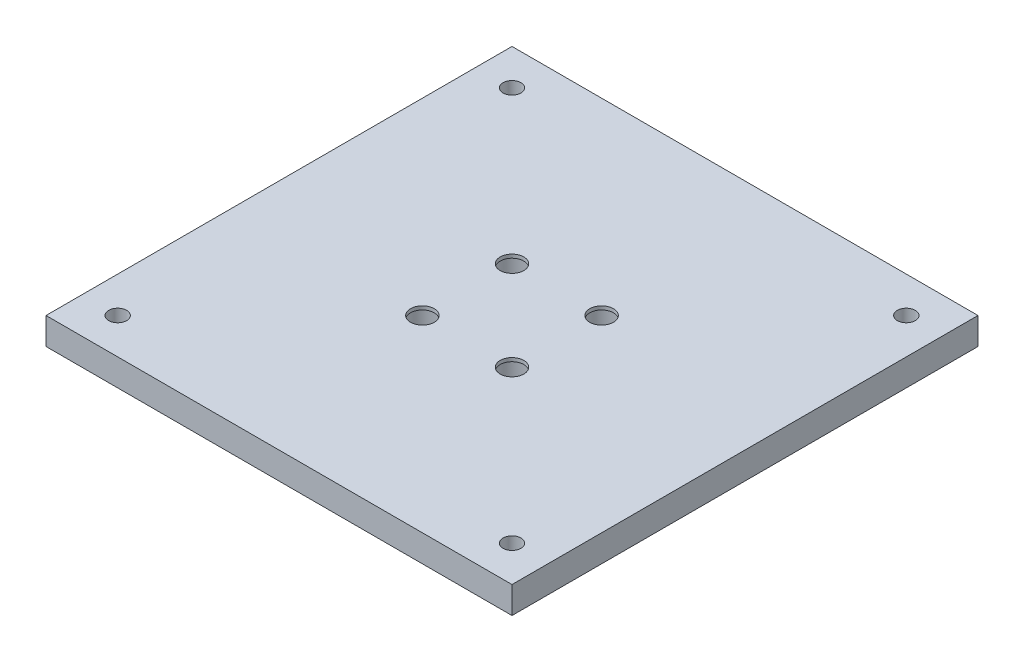
from build123d import *

# Parameters (mm, degrees)
SKETCH_1_W          = 130
SKETCH_1_H          = 130
EXTRUDE_1_DEPTH     = 7.5
HOLE_WIZARD_M6_2_D  = 5
SKETCH_6_R          = 5.4
CUT_EXTRUDE_1_DEPTH = 6.5
SKETCH_7_R          = 3.3
CUT_EXTRUDE_2_DEPTH = 2


with BuildPart() as part:
    # 草图1 → 凸台-拉伸1 (new body)
    with BuildSketch(Plane(origin=(0, 0, 0), x_dir=(1, 0, 0), z_dir=(0, 1, 0))):
        with Locations((65, 65)):
            Rectangle(SKETCH_1_W, SKETCH_1_H)
    extrude(amount=EXTRUDE_1_DEPTH)

    # M6 螺纹孔2 (through all)
    with Locations(Plane(origin=(10, 7.5, -120), x_dir=(0, 0, 1), z_dir=(0, 1, 0))):
        with Locations((0, 0), (0, 110), (110, 110), (110, 0)):
            Hole(HOLE_WIZARD_M6_2_D / 2)

    # 草图6 → 切除-拉伸1 (cut)
    with BuildSketch(Plane(origin=(0, 0, 0), x_dir=(-1, 0, 0), z_dir=(0, -1, 0))):
        with Locations((-52.5, 52.5)):
            Circle(SKETCH_6_R)
        with Locations((-77.5, 52.5)):
            Circle(SKETCH_6_R)
        with Locations((-52.5, 77.5)):
            Circle(SKETCH_6_R)
        with Locations((-77.5, 77.5)):
            Circle(SKETCH_6_R)
    extrude(amount=-CUT_EXTRUDE_1_DEPTH, mode=Mode.SUBTRACT)

    # 草图7 → 切除-拉伸2 (cut, through all)
    with BuildSketch(Plane.XZ.offset(-6.5)):
        with Locations((52.5, -52.5)):
            Circle(SKETCH_7_R)
        with Locations((77.5, -52.5)):
            Circle(SKETCH_7_R)
        with Locations((77.5, -77.5)):
            Circle(SKETCH_7_R)
        with Locations((52.5, -77.5)):
            Circle(SKETCH_7_R)
    extrude(amount=-CUT_EXTRUDE_2_DEPTH, mode=Mode.SUBTRACT)


solid = part.part
